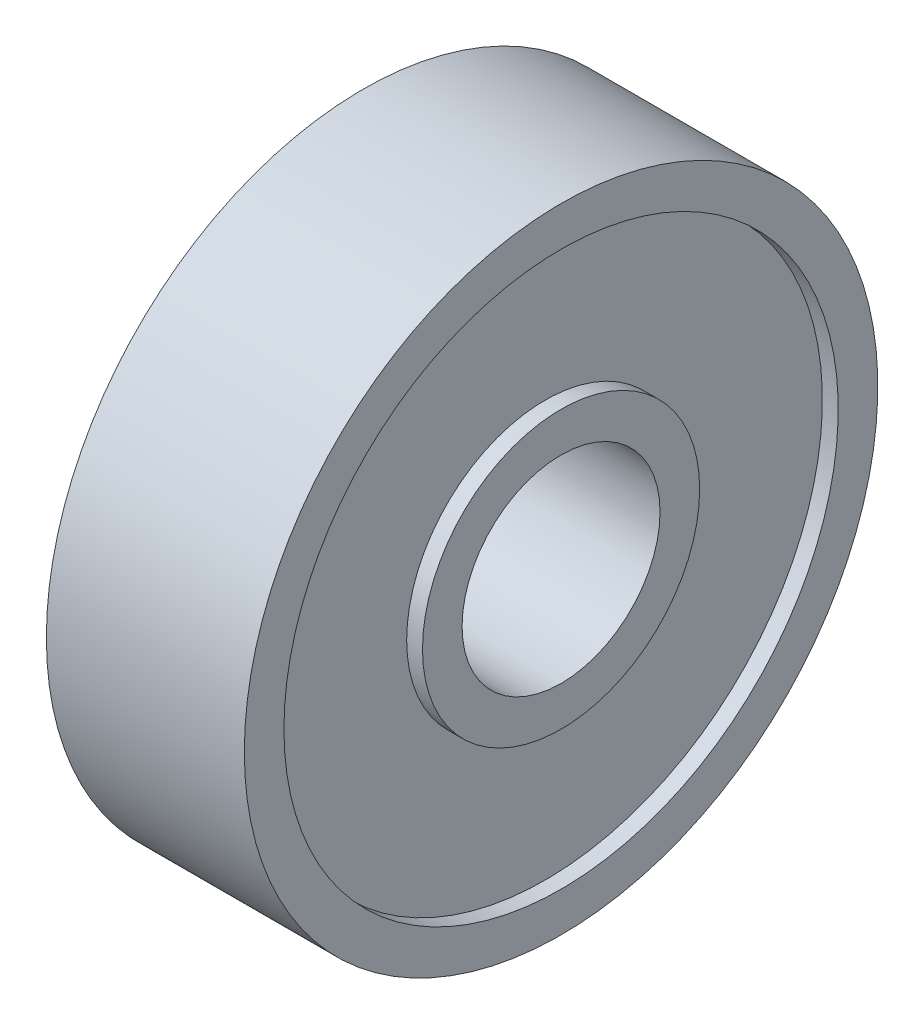
from build123d import *


with BuildPart() as part:
    # Sketch1 → Revolve1 (revolve)
    with BuildSketch(Plane.XY):
        Polygon((-2.5, 8), (2.5, 8), (2.5, 7), (2.1, 7), (2.1, 3.5), (2.5, 3.5), (2.5, 2.5), (-2.5, 2.5), (-2.5, 3.5), (-2.1, 3.5), (-2.1, 7), (-2.5, 7), align=None)
    revolve(axis=Axis((-2.5, 0, 0), (1, 0, 0)))


solid = part.part
